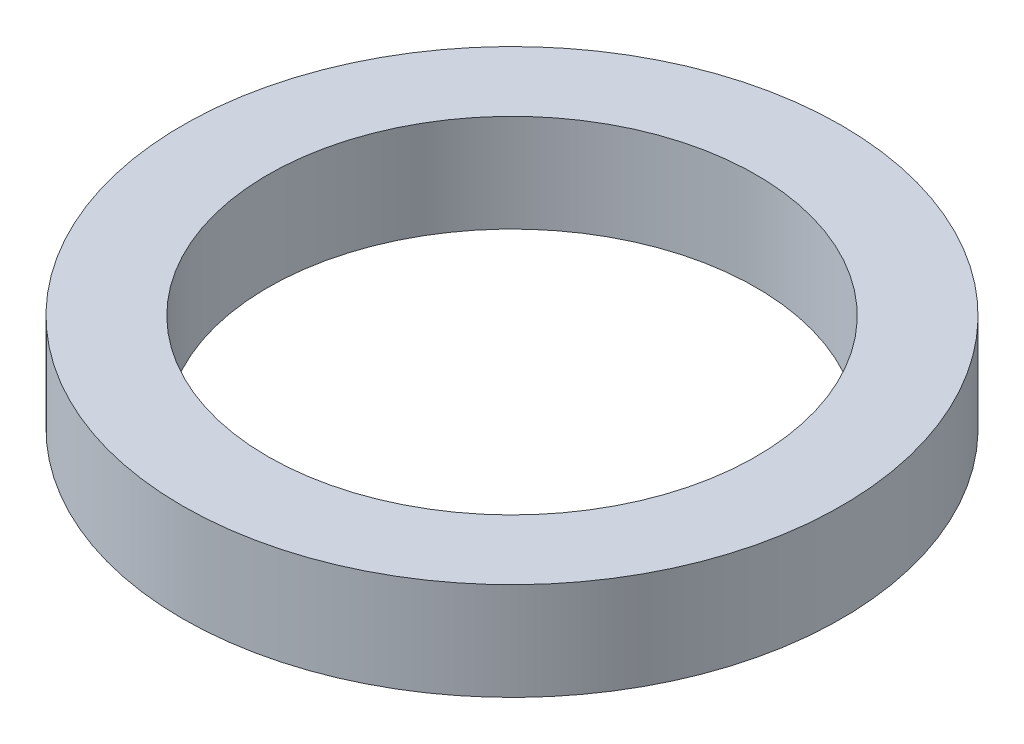
from build123d import *

# Parameters (mm, degrees)
SKETCH1_R           = 13.5
SKETCH1_R_2         = 10
BOSS_EXTRUDE1_DEPTH = 4


with BuildPart() as part:
    # Sketch1 → Boss-Extrude1 (new body)
    with BuildSketch(Plane(origin=(0, 0, 0), x_dir=(1, 0, 0), z_dir=(0, 1, 0))):
        Circle(SKETCH1_R)
        Circle(SKETCH1_R_2, mode=Mode.SUBTRACT)
    extrude(amount=BOSS_EXTRUDE1_DEPTH)


solid = part.part
